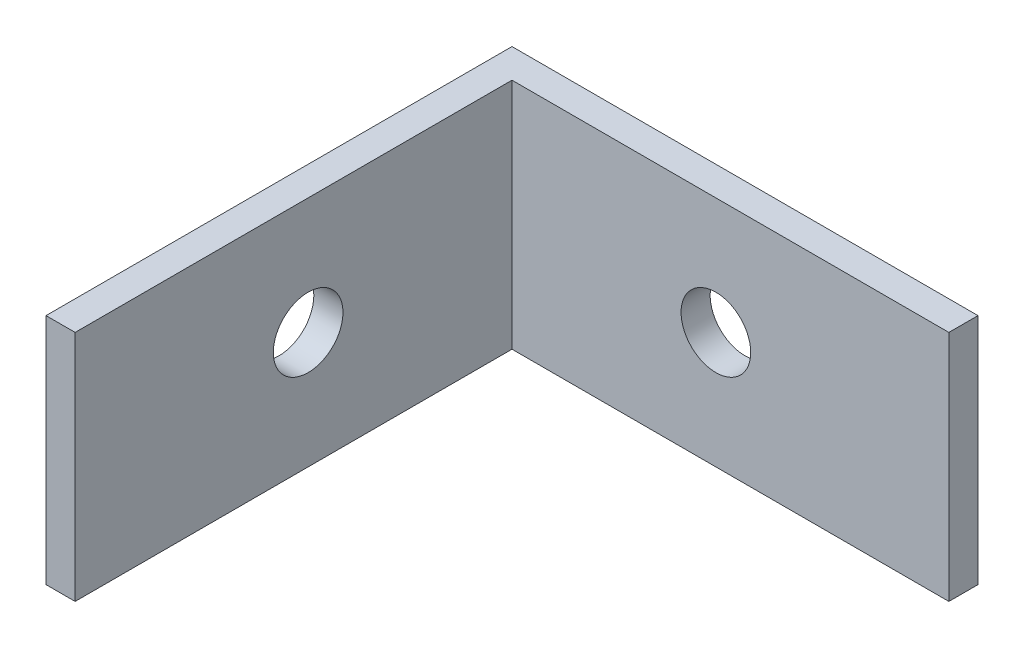
from build123d import *

# Parameters (mm, degrees)
BOSS_EXTRUDE1_DEPTH   = 12.7
F_6_CLEARANCE_HOLE2_D = 3.7973
F_6_CLEARANCE_HOLE1_D = 3.7973


with BuildPart() as part:
    # Sketch1 → Boss-Extrude1 (new body)
    with BuildSketch(Plane(origin=(0, 0, 0), x_dir=(1, 0, 0), z_dir=(0, 1, 0))):
        Polygon((0, -5.255172414), (0, 20.144827586), (25.4, 20.144827586), (25.4, 18.557327586), (1.5875, 18.557327586), (1.5875, -5.255172414), align=None)
    extrude(amount=BOSS_EXTRUDE1_DEPTH)

    # #6 Clearance Hole2 (through all)
    with Locations(Plane(origin=(1.5875, 0, 0), x_dir=(0, 0, -1), z_dir=(1, 0, 0))):
        with Locations((7.444827586, 6.35)):
            Hole(F_6_CLEARANCE_HOLE2_D / 2)

    # #6 Clearance Hole1 (through all)
    with Locations(Plane.XY.offset(-18.557327586)):
        with Locations((12.7, 6.35)):
            Hole(F_6_CLEARANCE_HOLE1_D / 2)


solid = part.part
